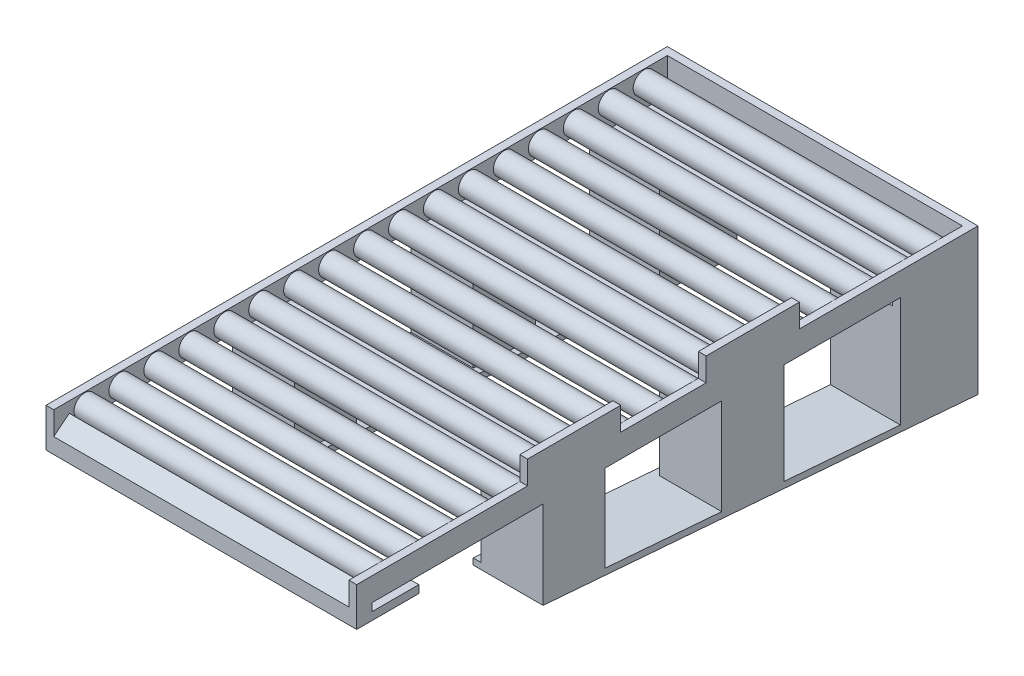
from build123d import *

# Parameters (mm, degrees)
SKETCH2_W               = 4000
SKETCH2_H               = 8000
SKETCH2_W_2             = 3800
SKETCH2_H_2             = 7800
BOSS_EXTRUDE1_DEPTH     = 300
SKETCH3_R               = 140
BOSS_EXTRUDE2_DEPTH     = 3800
LPATTERN1_COUNT         = 17
LPATTERN1_PITCH         = 450
BOSS_EXTRUDE3_DEPTH     = 200
SKETCH5_W               = 4000
SKETCH5_H               = 1000
BOSS_EXTRUDE4_DEPTH     = 57
SKETCH6_W               = 4000
SKETCH6_H               = 800
BOSS_EXTRUDE5_DEPTH     = 200
SKETCH7_W               = 4000
SKETCH7_H               = 800
BOSS_EXTRUDE6_DEPTH     = 200
SKETCH8_W               = 4000
SKETCH8_H               = 800
BOSS_EXTRUDE7_DEPTH     = 200
SKETCH9_W               = 3800
SKETCH9_H               = 300
CUT_EXTRUDE1_DEPTH      = 200
BOSS_EXTRUDE8_DEPTH     = 3800
SKETCH11_W              = 1200
SKETCH11_H              = 300
BOSS_EXTRUDE9_DEPTH     = 100
SKETCH12_W              = 900
SKETCH12_H              = 1000
BOSS_EXTRUDE10_DEPTH    = 1300
SKETCH13_W              = 800
SKETCH13_H              = 800
BOSS_EXTRUDE11_DEPTH    = 1100
BOSS_EXTRUDE12_DEPTH    = 800
BOSS_EXTRUDE13_DEPTH    = 900
BOSS_EXTRUDE15_DEPTH    = 4000
CUT_EXTRUDE3_DEPTH      = 4001
BOSS_EXTRUDE16_START    = -2000
BOSS_EXTRUDE16_DEPTH    = 4000
BOSS_EXTRUDE17_REACH    = 1382
SKETCH20_W              = 800
SKETCH20_H              = 800
BOSS_EXTRUDE18_REACH    = 1382
SKETCH28_W              = 800
SKETCH28_H              = 800
SKETCH29_W              = 2200
SKETCH29_H              = 1745.936228959
CUT_EXTRUDE4_DEPTH      = 4001
CUT_EXTRUDE4_DEPTH_BACK = 4000
SKETCH30_W              = 2459.672071775
SKETCH30_H              = 1784.301362594
CUT_EXTRUDE5_DEPTH      = 2000
SKETCH31_W              = 602.15892419
SKETCH31_H              = 100
CUT_EXTRUDE6_DEPTH      = 4000


with BuildPart() as part:
    # Sketch2 → Boss-Extrude1 (new body)
    with BuildSketch(Plane(origin=(0, 0, 0), x_dir=(1, 0, 0), z_dir=(0, 1, 0))):
        Rectangle(SKETCH2_W, SKETCH2_H)
        Rectangle(SKETCH2_W_2, SKETCH2_H_2, mode=Mode.SUBTRACT)
    extrude(amount=BOSS_EXTRUDE1_DEPTH)

    # Sketch3 → Boss-Extrude2 (add)
    with BuildSketch(Plane(origin=(-1900, 0, 0), x_dir=(0, 0, -1), z_dir=(1, 0, 0))):
        with Locations((3600, 150)):
            Circle(SKETCH3_R)
    boss_extrude2 = extrude(amount=BOSS_EXTRUDE2_DEPTH)

    # LPattern1: Boss-Extrude2 ×17
    with Locations(*[(0, 0, i * LPATTERN1_PITCH) for i in range(1, LPATTERN1_COUNT)]):
        add(boss_extrude2)

    # Sketch4 → Boss-Extrude3 (add)
    with BuildSketch(Plane.XZ):
        Polygon((-1900, -3000), (-2000, -3000), (-2000, -4000), (2000, -4000), (2000, -3000), (1900, -3000), (1900, -3900), (-1900, -3900), align=None)
    extrude(amount=BOSS_EXTRUDE3_DEPTH)

    # Sketch5 → Boss-Extrude4 (add)
    with BuildSketch(Plane.XZ.offset(200)):
        with Locations((0, -3500)):
            Rectangle(SKETCH5_W, SKETCH5_H)
    extrude(amount=-BOSS_EXTRUDE4_DEPTH)

    # Sketch6 → Boss-Extrude5 (add)
    with BuildSketch(Plane(origin=(0, 0, 0), x_dir=(-1, 0, 0), z_dir=(0, -1, 0))):
        with Locations((0, -3600)):
            Rectangle(SKETCH6_W, SKETCH6_H)
    extrude(amount=BOSS_EXTRUDE5_DEPTH)

    # Sketch7 → Boss-Extrude6 (add)
    with BuildSketch(Plane(origin=(0, 0, 0), x_dir=(-1, 0, 0), z_dir=(0, -1, 0))):
        with Locations((0, 1100)):
            Rectangle(SKETCH7_W, SKETCH7_H)
    extrude(amount=BOSS_EXTRUDE6_DEPTH)

    # Sketch8 → Boss-Extrude7 (add)
    with BuildSketch(Plane(origin=(0, 0, 0), x_dir=(-1, 0, 0), z_dir=(0, -1, 0))):
        with Locations((0, -1200)):
            Rectangle(SKETCH8_W, SKETCH8_H)
    extrude(amount=BOSS_EXTRUDE7_DEPTH)

    # Sketch9 → Cut-Extrude1 (cut)
    with BuildSketch(Plane(origin=(0, 0, 3900), x_dir=(-1, 0, 0), z_dir=(0, 0, -1))):
        with Locations((0, 150)):
            Rectangle(SKETCH9_W, SKETCH9_H)
    extrude(amount=-CUT_EXTRUDE1_DEPTH, mode=Mode.SUBTRACT)

    # Sketch10 → Boss-Extrude8 (add)
    with BuildSketch(Plane(origin=(-1900, 0, 0), x_dir=(0, 0, -1), z_dir=(1, 0, 0))):
        Polygon((-4000, 0), (-3800, 160), (-3800, 0), align=None)
    extrude(amount=BOSS_EXTRUDE8_DEPTH)

    # Sketch11 → Boss-Extrude9 (add)
    with BuildSketch(Plane(origin=(2000, 0, 0), x_dir=(0, 0, -1), z_dir=(1, 0, 0))):
        with Locations((1100, 450)):
            Rectangle(SKETCH11_W, SKETCH11_H)
        with Locations((-1200, 450)):
            Rectangle(SKETCH11_W, SKETCH11_H)
    extrude(amount=-BOSS_EXTRUDE9_DEPTH)

    # Sketch12 → Boss-Extrude10 (add)
    with BuildSketch(Plane.XZ.offset(200)):
        with Locations((-1550, -3500)):
            Rectangle(SKETCH12_W, SKETCH12_H)
        with Locations((1550, -3500)):
            Rectangle(SKETCH12_W, SKETCH12_H)
    extrude(amount=BOSS_EXTRUDE10_DEPTH)

    # Sketch13 → Boss-Extrude11 (add)
    with BuildSketch(Plane.XZ.offset(200)):
        with Locations((-1600, -1100)):
            Rectangle(SKETCH13_W, SKETCH13_H)
        with Locations((1600, -1100)):
            Rectangle(SKETCH13_W, SKETCH13_H)
    extrude(amount=BOSS_EXTRUDE11_DEPTH)

    # Sketch14 → Boss-Extrude12 (add)
    with BuildSketch(Plane(origin=(2000, 0, 0), x_dir=(0, 0, -1), z_dir=(1, 0, 0))):
        Polygon((700, -1300), (1500, -1380), (1500, -1300), align=None)
    extrude(amount=-BOSS_EXTRUDE12_DEPTH)



with BuildPart() as body_2:
    # Sketch16 → Boss-Extrude13 (new body)
    with BuildSketch(Plane(origin=(2000, 0, 0), x_dir=(0, 0, -1), z_dir=(1, 0, 0))):
        Polygon((3000, -1500), (4000, -1580), (4000, -1500), align=None)
    extrude(amount=-BOSS_EXTRUDE13_DEPTH)


with BuildPart() as part_1:
    add(part.part)

    add(body_2.part)  # Boss-Extrude15 merges body 2
    # Sketch21 → Boss-Extrude15 (add)
    with BuildSketch(Plane.ZY.offset(2000)):
        Polygon((-4000, -1500), (-4000, -1580), (-3000, -1500), align=None)
    extrude(amount=-BOSS_EXTRUDE15_DEPTH)

    # Sketch24 → Cut-Extrude3 (cut, through all)
    with BuildSketch(Plane(origin=(2000, 0, 0), x_dir=(0, 0, -1), z_dir=(1, 0, 0))):
        Polygon((700, -1300), (1500, -1300), (1500, -1380), align=None)
    extrude(amount=-CUT_EXTRUDE3_DEPTH, mode=Mode.SUBTRACT)

    # Sketch27 → Boss-Extrude16 (add)
    with BuildSketch(Plane(origin=(0, 0, 0), x_dir=(0, 0, -1), z_dir=(1, 0, 0)).offset(BOSS_EXTRUDE16_START)):
        Polygon((4000, -1580), (-4000, -940), (-4000, -860), (4000, -1500), align=None)
    extrude(amount=BOSS_EXTRUDE16_DEPTH)

    # Boss-Extrude17: up to this face of the body (flat: up to its plane)
    boss_extrude17_end = Plane(part_1.part.faces().sort_by_distance((0, -1158.677731674, 266.52835408))[0])
    # Sketch20 → Boss-Extrude17 (add, up to the picked face)
    with BuildSketch(Plane.XZ.offset(200), mode=Mode.PRIVATE) as boss_extrude17_sk1:
        with Locations((-1600, 1200)):
            Rectangle(SKETCH20_W, SKETCH20_H)
    boss_extrude17_tool1 = split(extrude(boss_extrude17_sk1.sketch, amount=BOSS_EXTRUDE17_REACH, mode=Mode.PRIVATE), bisect_by=boss_extrude17_end, keep=Keep.BOTH, mode=Mode.PRIVATE)
    add(boss_extrude17_tool1.solids().sort_by_distance((-1600, -200, 1200))[0])

    # Boss-Extrude18: up to this face of the body (flat: up to its plane)
    boss_extrude18_end = Plane(part_1.part.faces().sort_by_distance((36.209335219, -1160.367751061, 245.40311174))[0])
    # Sketch28 → Boss-Extrude18 (add, up to the picked face)
    with BuildSketch(Plane.XZ.offset(200), mode=Mode.PRIVATE) as boss_extrude18_sk1:
        with Locations((1600, 1200)):
            Rectangle(SKETCH28_W, SKETCH28_H)
    boss_extrude18_tool1 = split(extrude(boss_extrude18_sk1.sketch, amount=BOSS_EXTRUDE18_REACH, mode=Mode.PRIVATE), bisect_by=boss_extrude18_end, keep=Keep.BOTH, mode=Mode.PRIVATE)
    add(boss_extrude18_tool1.solids().sort_by_distance((1600, -200, 1200))[0])

    # Sketch29 → Cut-Extrude4 (cut, two sides)
    with BuildSketch(Plane.XY) as cut_extrude4_sk:
        with Locations((0, -1252.772345586)):
            Rectangle(SKETCH29_W, SKETCH29_H)
    extrude(amount=CUT_EXTRUDE4_DEPTH, mode=Mode.SUBTRACT)
    extrude(cut_extrude4_sk.sketch, amount=-CUT_EXTRUDE4_DEPTH_BACK, mode=Mode.SUBTRACT)

    # Sketch30 → Cut-Extrude5 (cut, symmetric)
    with BuildSketch(Plane(origin=(0, 0, 0), x_dir=(0, 0, -1), z_dir=(1, 0, 0))):
        with Locations((-2829.836035888, -1280.25847445)):
            Rectangle(SKETCH30_W, SKETCH30_H)
    extrude(amount=CUT_EXTRUDE5_DEPTH, both=True, mode=Mode.SUBTRACT)

    # Sketch31 → Cut-Extrude6 (cut)
    with BuildSketch(Plane.ZY.offset(2000)):
        with Locations((3501.079462095, -50)):
            Rectangle(SKETCH31_W, SKETCH31_H)
    extrude(amount=-CUT_EXTRUDE6_DEPTH, mode=Mode.SUBTRACT)


solid = part_1.part
